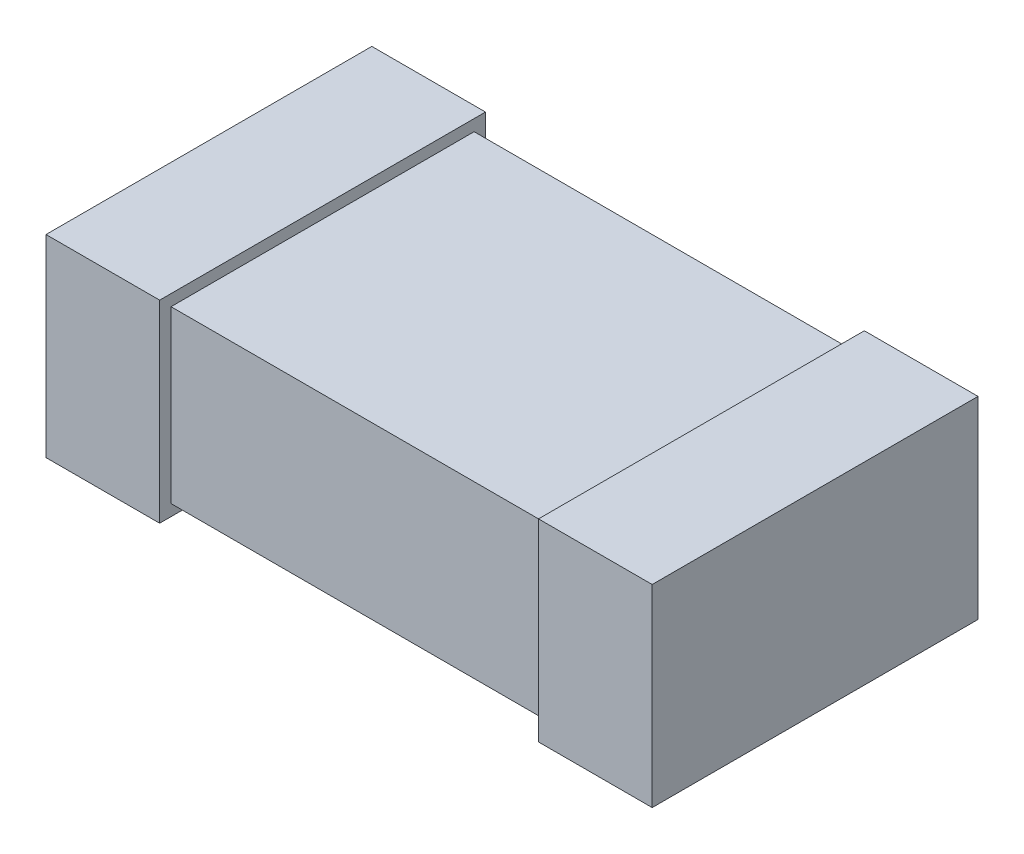
from build123d import *

# Parameters (mm, degrees)
SKETCH1_W           = 1.6
SKETCH1_H           = 0.8
EXTRUDE1_DEPTH      = 0.45
SKETCH2_W           = 0.3
SKETCH2_H           = 0.51
EXTRUDE2_DEPTH      = 0.43
EXTRUDE2_DEPTH_BACK = 0.43


with BuildPart() as part:
    # Sketch1 → Extrude1 (new body)
    with BuildSketch(Plane(origin=(0, 0, 0), x_dir=(1, 0, 0), z_dir=(0, 1, 0))):
        Rectangle(SKETCH1_W, SKETCH1_H)
    extrude(amount=EXTRUDE1_DEPTH)

    # Sketch2 → Extrude2 (add, two sides)
    with BuildSketch(Plane.XY) as extrude2_sk:
        with Locations((-0.65, 0.225)):
            Rectangle(SKETCH2_W, SKETCH2_H)
        with Locations((0.65, 0.225)):
            Rectangle(SKETCH2_W, SKETCH2_H)
    extrude(amount=EXTRUDE2_DEPTH)
    extrude(extrude2_sk.sketch, amount=-EXTRUDE2_DEPTH_BACK)


solid = part.part
